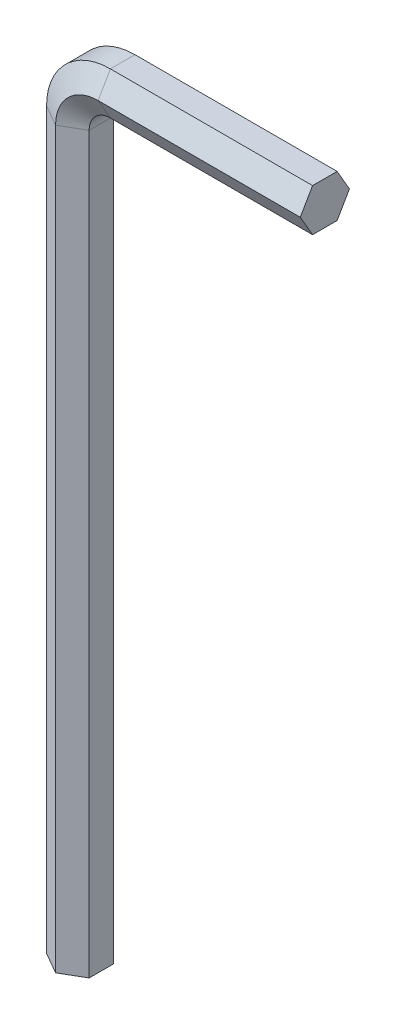
from build123d import *


with BuildPart() as part:
    # Sweep1: sweep along a path in Sketch2
    with BuildLine(Plane.XY) as sweep1_path:
        Line((0, 0), (0, 69))
        ThreePointArc((0, 69), (1.757359313, 73.242640687), (6, 75))
        Line((6, 75), (25, 75))
    # Sketch3 → Sweep1 (sweep)
    with BuildSketch(Plane(origin=(0, 0, 0), x_dir=(1, 0, 0), z_dir=(0, 1, 0))):
        Polygon((2, 2.309401077), (0, 1.154700538), (0, -1.154700538), (2, -2.309401077), (4, -1.154700538), (4, 1.154700538), align=None)
    sweep(path=sweep1_path.line)


solid = part.part
